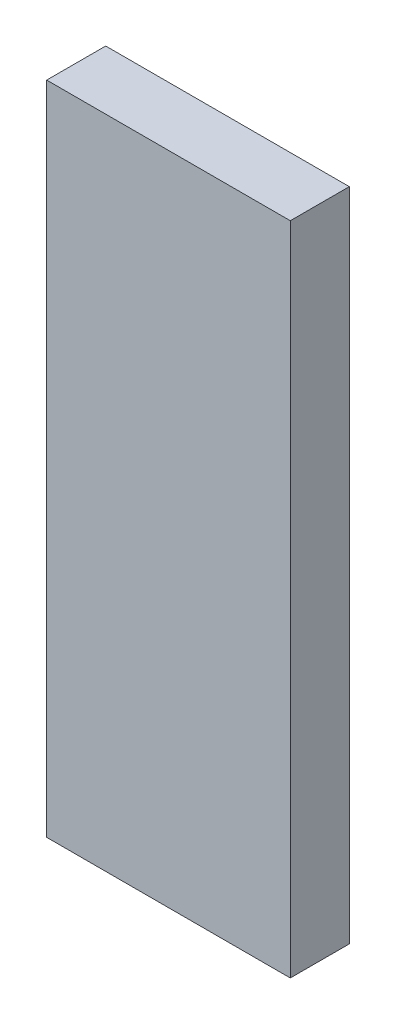
from build123d import *

# Parameters (mm, degrees)
SKETCH1_W           = 16.51
SKETCH1_H           = 44.45
BOSS_EXTRUDE1_DEPTH = 4


with BuildPart() as part:
    # Sketch1 → Boss-Extrude1 (new body)
    with BuildSketch(Plane.XY):
        with Locations((8.255, 22.225)):
            Rectangle(SKETCH1_W, SKETCH1_H)
    extrude(amount=BOSS_EXTRUDE1_DEPTH)


solid = part.part
